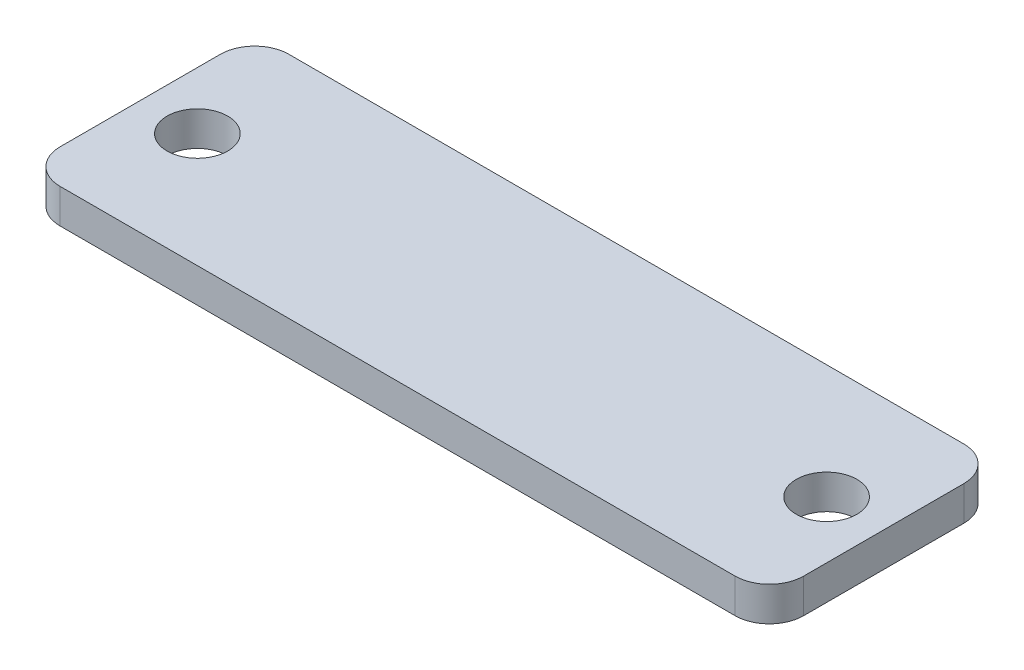
from build123d import *

# Parameters (mm, degrees)
BOSS_EXTRUDE1_DEPTH  = 3
M3_CLEARANCE_HOLE1_D = 3.2
M5_CLEARANCE_HOLE1_D = 5.3
SKETCH8_W            = 65
SKETCH8_H            = 21.5
CUT_EXTRUDE1_DEPTH   = 4
FILLET2_R            = 3


with BuildPart() as part:
    # Sketch1 → Boss-Extrude1 (new body)
    with BuildSketch(Plane(origin=(0, 0, 0), x_dir=(1, 0, 0), z_dir=(0, 1, 0))):
        with BuildLine():
            Line((32.5, -29), (32.5, -9))
            Line((32.5, -9), (7.563621408, 9.951966197))
            ThreePointArc((7.563621408, 9.951966197), (0, 12.5), (-7.563621408, 9.951966197))
            Line((-7.563621408, 9.951966197), (-32.5, -9))
            Line((-32.5, -9), (-32.5, -29))
            Line((-32.5, -29), (32.5, -29))
        make_face()
        with BuildLine():
            ThreePointArc((-4, 0), (0, 4), (4, 0))
            ThreePointArc((4, 0), (0, -4), (-4, 0))
        make_face(mode=Mode.SUBTRACT)
    extrude(amount=BOSS_EXTRUDE1_DEPTH)

    # M3 Clearance Hole1 (through all)
    with Locations(Plane(origin=(0, 0, 0), x_dir=(-1, 0, 0), z_dir=(0, -1, 0))):
        with Locations((8.5, 0), (-8.5, 0)):
            Hole(M3_CLEARANCE_HOLE1_D / 2)

    # M5 Clearance Hole1 (through all)
    with Locations(Plane(origin=(0, 0, 0), x_dir=(-1, 0, 0), z_dir=(0, -1, 0))):
        with Locations((-27.5, -19), (27.5, -19)):
            Hole(M5_CLEARANCE_HOLE1_D / 2)

    # Sketch8 → Cut-Extrude1 (cut, through all)
    with BuildSketch(Plane(origin=(0, 0, 0), x_dir=(1, 0, 0), z_dir=(0, 1, 0))):
        with Locations((0, 1.75)):
            Rectangle(SKETCH8_W, SKETCH8_H)
    extrude(amount=CUT_EXTRUDE1_DEPTH, mode=Mode.SUBTRACT)

    # Fillet2
    fillet2_edges = [part.edges().sort_by_distance(p)[0] for p in [
        (32.5, 1.5, 9),
        (32.5, 1.5, 29),
        (-32.5, 1.5, 29),
        (-32.5, 1.5, 9),
    ]]
    fillet(fillet2_edges, radius=FILLET2_R)


solid = part.part
